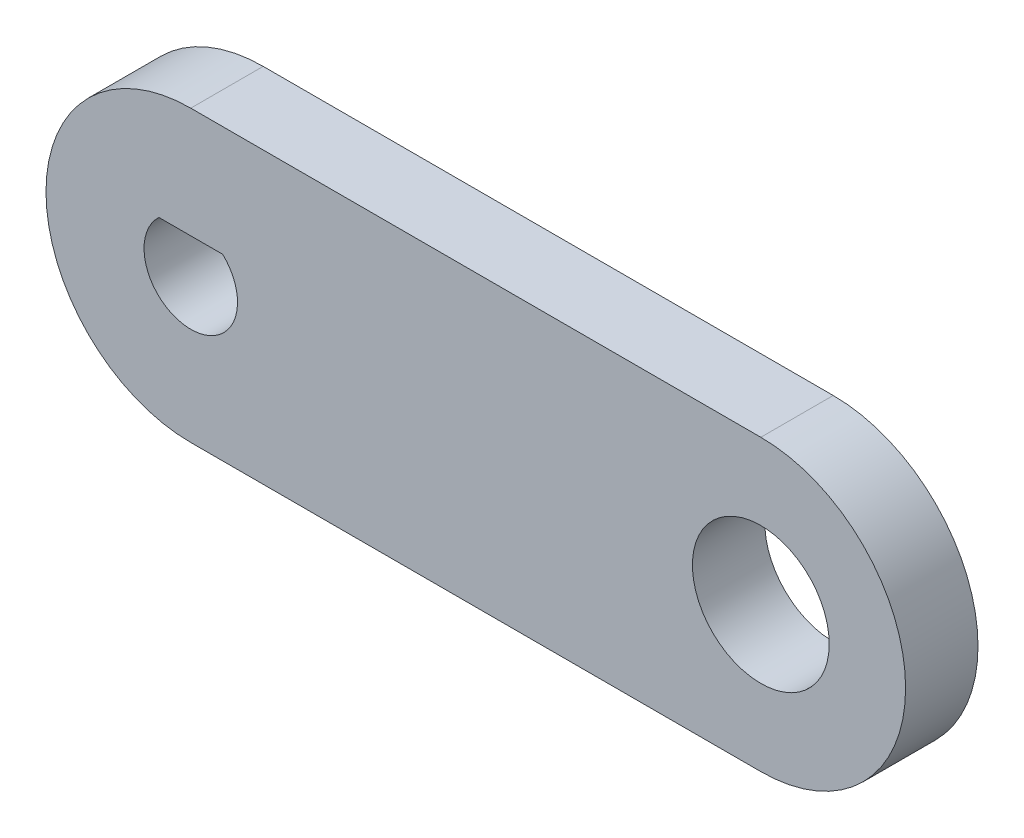
from build123d import *

# Parameters (mm, degrees)
SKETCH1_R      = 3
EXTRUDE1_DEPTH = 3.175


with BuildPart() as part:
    # Sketch1 → Extrude1 (new body)
    with BuildSketch(Plane.XY):
        with BuildLine():
            Line((25, 6.35), (0, 6.35))
            ThreePointArc((0, 6.35), (-6.35, 0), (0, -6.35))
            Line((0, -6.35), (25, -6.35))
            ThreePointArc((25, -6.35), (31.35, 0), (25, 6.35))
        make_face()
        with Locations((25, 0)):
            Circle(SKETCH1_R, mode=Mode.SUBTRACT)
        with BuildLine():
            Line((-1.397318861, 1.5), (1.397318861, 1.5))
            ThreePointArc((1.397318861, 1.5), (0, -2.05), (-1.397318861, 1.5))
        make_face(mode=Mode.SUBTRACT)
    extrude(amount=-EXTRUDE1_DEPTH)


solid = part.part
